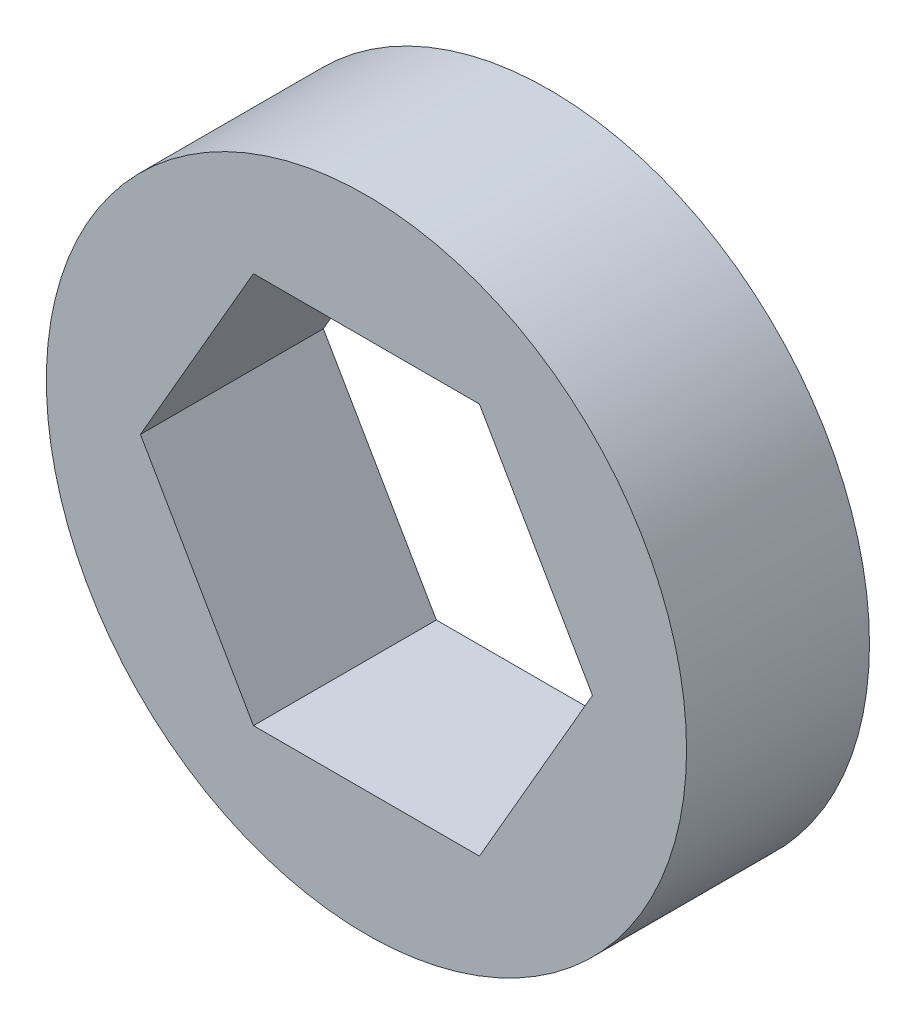
from build123d import *

# Parameters (mm, degrees)
SKETCH1_R           = 11.1125
BOSS_EXTRUDE1_DEPTH = 6.35


with BuildPart() as part:
    # Sketch1 → Boss-Extrude1 (new body)
    with BuildSketch(Plane.XY):
        Circle(SKETCH1_R)
        Polygon((7.845612808, 0), (3.922806404, 6.7945), (-3.922806404, 6.7945), (-7.845612808, 0), (-3.922806404, -6.7945), (3.922806404, -6.7945), align=None, mode=Mode.SUBTRACT)
    extrude(amount=BOSS_EXTRUDE1_DEPTH)


solid = part.part
